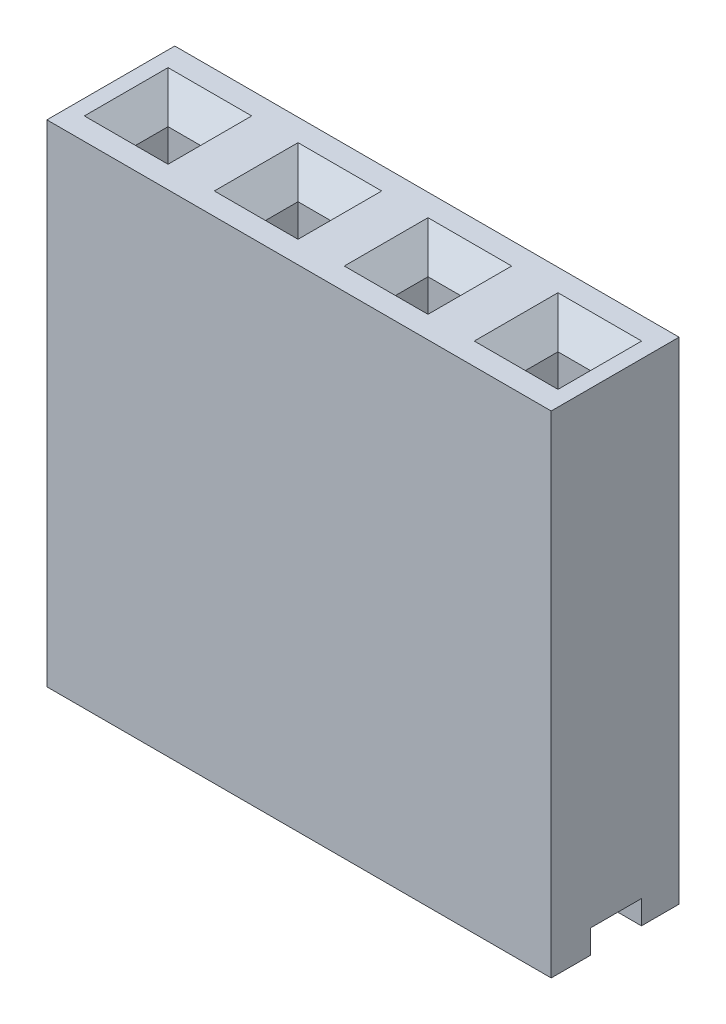
from build123d import *

# Parameters (mm, degrees)
CROQUIS1_W              = 9.859
CROQUIS1_H              = 2.5
CROQUIS1_W_2            = 0.636
CROQUIS1_H_2            = 0.636
SALIENTE_EXTRUIR2_DEPTH = 9.6
CHAFL_N2_SIZE           = 0.5
CHAFL_N3_SIZE           = 0.5
CROQUIS2_W              = 1.000954756
CROQUIS2_H              = 0.463176593
CORTAR_EXTRUIR1_DEPTH   = 10.859


with BuildPart() as part:
    # Croquis1 → Saliente-Extruir2 (new body)
    with BuildSketch(Plane(origin=(0, 0, 0), x_dir=(1, 0, 0), z_dir=(0, 1, 0))):
        with Locations((4.9295, -1.25)):
            Rectangle(CROQUIS1_W, CROQUIS1_H)
        with Locations((1.118, -1.25)):
            Rectangle(CROQUIS1_W_2, CROQUIS1_H_2, mode=Mode.SUBTRACT)
        with Locations((3.659, -1.25)):
            Rectangle(CROQUIS1_W_2, CROQUIS1_H_2, mode=Mode.SUBTRACT)
        with Locations((8.741, -1.25)):
            Rectangle(CROQUIS1_W_2, CROQUIS1_H_2, mode=Mode.SUBTRACT)
        with Locations((6.2, -1.25)):
            Rectangle(CROQUIS1_W_2, CROQUIS1_H_2, mode=Mode.SUBTRACT)
    extrude(amount=SALIENTE_EXTRUIR2_DEPTH)

    # Chaflán2
    chafl_n2_edges = [part.edges().sort_by_distance(p)[0] for p in [
        (0.8, 9.6, 1.25),
        (1.118, 9.6, 1.568),
        (1.436, 9.6, 1.25),
        (1.118, 9.6, 0.932),
    ]]
    chamfer(chafl_n2_edges, length=CHAFL_N2_SIZE)

    # Chaflán3
    chafl_n3_edges = [part.edges().sort_by_distance(p)[0] for p in [
        (3.659, 9.6, 0.932),
        (3.341, 9.6, 1.25),
        (3.659, 9.6, 1.568),
        (3.977, 9.6, 1.25),
        (8.741, 9.6, 0.932),
        (8.423, 9.6, 1.25),
        (8.741, 9.6, 1.568),
        (9.059, 9.6, 1.25),
        (6.2, 9.6, 0.932),
        (5.882, 9.6, 1.25),
        (6.2, 9.6, 1.568),
        (6.518, 9.6, 1.25),
    ]]
    chamfer(chafl_n3_edges, length=CHAFL_N3_SIZE)

    # Croquis2 → Cortar-Extruir1 (cut, through all)
    with BuildSketch(Plane.ZY):
        with Locations((1.236111308, 0.231588297)):
            Rectangle(CROQUIS2_W, CROQUIS2_H)
    extrude(amount=-CORTAR_EXTRUIR1_DEPTH, mode=Mode.SUBTRACT)


solid = part.part
